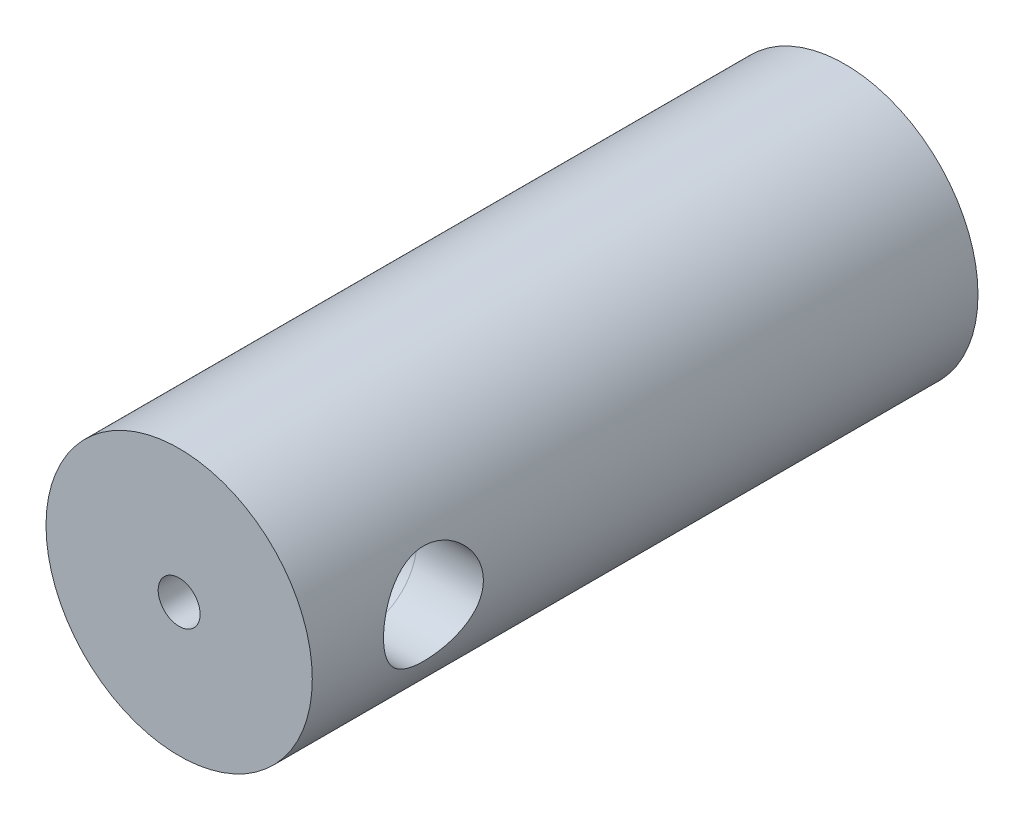
from build123d import *

# Parameters (mm, degrees)
SKETCH1_R           = 20
BOSS_EXTRUDE1_DEPTH = 100
SKETCH3_R           = 3.15
CUT_EXTRUDE2_DEPTH  = 5
SKETCH2_R           = 7.5
SKETCH6_R           = 9.75
SKETCH6_W           = 5
SKETCH6_H           = 7.292344614
CUT_EXTRUDE3_DEPTH  = 10


with BuildPart() as part:
    # Sketch1 → Boss-Extrude1 (new body)
    with BuildSketch(Plane.XY):
        Circle(SKETCH1_R)
    extrude(amount=BOSS_EXTRUDE1_DEPTH)

    # Sketch3 → Cut-Extrude2 (cut)
    with BuildSketch(Plane.XY.offset(100)):
        Circle(SKETCH3_R)
    extrude(amount=-CUT_EXTRUDE2_DEPTH, mode=Mode.SUBTRACT)

    # Cut-Sweep1: sweep along a path in Sketch4
    with BuildLine(Plane(origin=(0, 0, 0), x_dir=(1, 0, 0), z_dir=(0, 1, 0))) as cut_sweep1_path:
        Line((0, 0), (0, -71.793883449))
        ThreePointArc((0, -71.793883449), (2.928932188, -78.864951261), (10, -81.793883449))
        Line((10, -81.793883449), (20, -81.793883449))
    # Sketch2 → Cut-Sweep1 (sweep, cut)
    with BuildSketch(Plane(origin=(0, 0, 0), x_dir=(-1, 0, 0), z_dir=(0, 0, -1))):
        Circle(SKETCH2_R)
    sweep(path=cut_sweep1_path.line, mode=Mode.SUBTRACT)

    # Sketch6 → Cut-Extrude3 (cut)
    with BuildSketch(Plane.XY):
        Circle(SKETCH6_R)
        with Locations((0, 10.103827693)):
            Rectangle(SKETCH6_W, SKETCH6_H)
    extrude(amount=CUT_EXTRUDE3_DEPTH, mode=Mode.SUBTRACT)


solid = part.part
